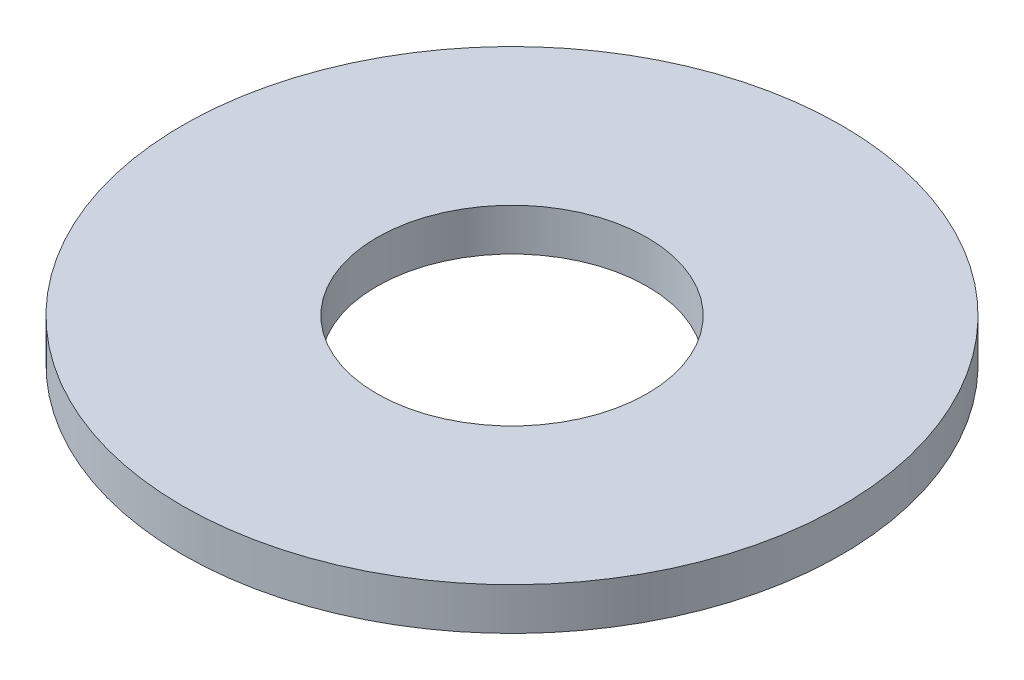
from build123d import *

# Parameters (mm, degrees)
SKETCH1_R      = 3.9
SKETCH1_R_2    = 1.6
EXTRUDE1_DEPTH = 0.5


with BuildPart() as part:
    # Sketch1 → Extrude1 (new body)
    with BuildSketch(Plane(origin=(0, 0, 0), x_dir=(1, 0, 0), z_dir=(0, 1, 0))):
        with Locations(Location((0, 0, 0), (0, 0, 270))):  # turned: the seam where the file's is
            Circle(SKETCH1_R)
        with Locations(Location((0, 0, 0), (0, 0, 270))):  # turned: the seam where the file's is
            Circle(SKETCH1_R_2, mode=Mode.SUBTRACT)
    extrude(amount=EXTRUDE1_DEPTH)


solid = part.part
